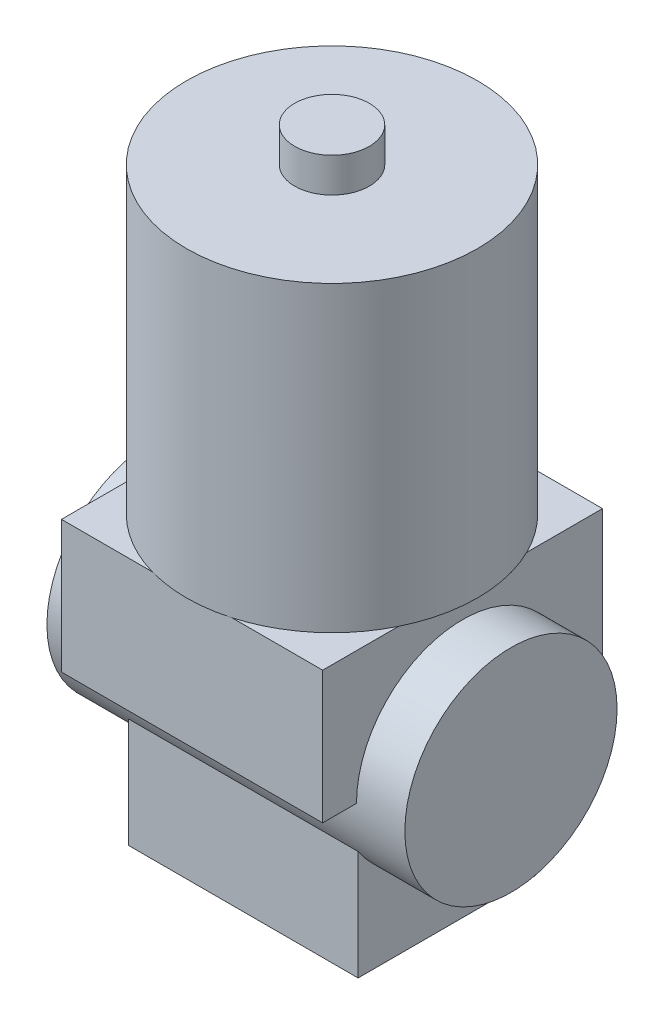
from build123d import *

# Parameters (mm, degrees)
SKETCH1_R                = 15.595
BOSS_EXTRUDE1_DEPTH      = 32.43
SKETCH2_R                = 4
BOSS_EXTRUDE2_DEPTH      = 3.7
SKETCH3_W                = 28
SKETCH3_H                = 30
BOSS_EXTRUDE3_DEPTH      = 14.18
SKETCH5_R                = 11.375
BOSS_EXTRUDE4_DEPTH      = 19.185
BOSS_EXTRUDE4_DEPTH_BACK = 19.185
SKETCH7_W                = 24.6
SKETCH7_H                = 19
BOSS_EXTRUDE5_DEPTH      = 18
SKETCH8_R                = 1.74191559
CUT_EXTRUDE1_DEPTH       = 18


with BuildPart() as part:
    # Sketch1 → Boss-Extrude1 (new body)
    with BuildSketch(Plane(origin=(0, 0, 0), x_dir=(1, 0, 0), z_dir=(0, 1, 0))):
        Circle(SKETCH1_R)
    extrude(amount=BOSS_EXTRUDE1_DEPTH)

    # Sketch2 → Boss-Extrude2 (add)
    with BuildSketch(Plane(origin=(0, 32.43, 0), x_dir=(1, 0, 0), z_dir=(0, 1, 0))):
        Circle(SKETCH2_R)
    extrude(amount=BOSS_EXTRUDE2_DEPTH)

    # Sketch3 → Boss-Extrude3 (add)
    with BuildSketch(Plane.XZ):
        Rectangle(SKETCH3_W, SKETCH3_H)
    extrude(amount=BOSS_EXTRUDE3_DEPTH)

    # Sketch5 → Boss-Extrude4 (add, two sides)
    with BuildSketch(Plane.ZY) as boss_extrude4_sk:
        with Locations((0, -14.18)):
            Circle(SKETCH5_R)
    extrude(amount=BOSS_EXTRUDE4_DEPTH)
    extrude(boss_extrude4_sk.sketch, amount=-BOSS_EXTRUDE4_DEPTH_BACK)

    # Sketch7 → Boss-Extrude5 (add)
    with BuildSketch(Plane.XZ.offset(14.18)):
        Rectangle(SKETCH7_W, SKETCH7_H)
    extrude(amount=BOSS_EXTRUDE5_DEPTH)

    # Sketch8 → Cut-Extrude1 (cut)
    with BuildSketch(Plane.XZ.offset(32.18)):
        with Locations((0, 5.595)):
            Circle(SKETCH8_R)
        with Locations((0, -5.595)):
            Circle(SKETCH8_R)
    extrude(amount=-CUT_EXTRUDE1_DEPTH, mode=Mode.SUBTRACT)


solid = part.part
